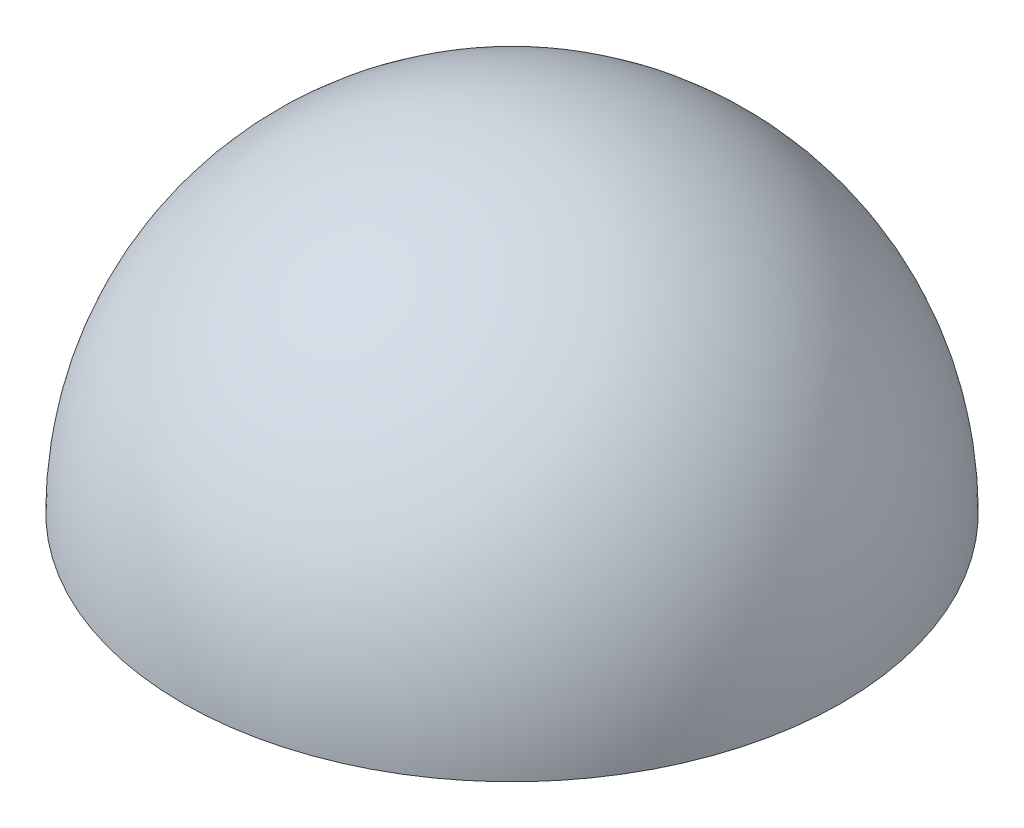
from build123d import *


with BuildPart() as part:
    # 草图1 → 旋转1 (revolve)
    with BuildSketch(Plane.XY):
        with BuildLine():
            Line((0, 0), (-70, 0))
            ThreePointArc((-70, 0), (-49.497474683, 49.497474683), (0, 70))
            Line((0, 70), (0, 0))
        make_face()
    revolve(axis=Axis((0, 0, 0), (0, 1, 0)))


solid = part.part
